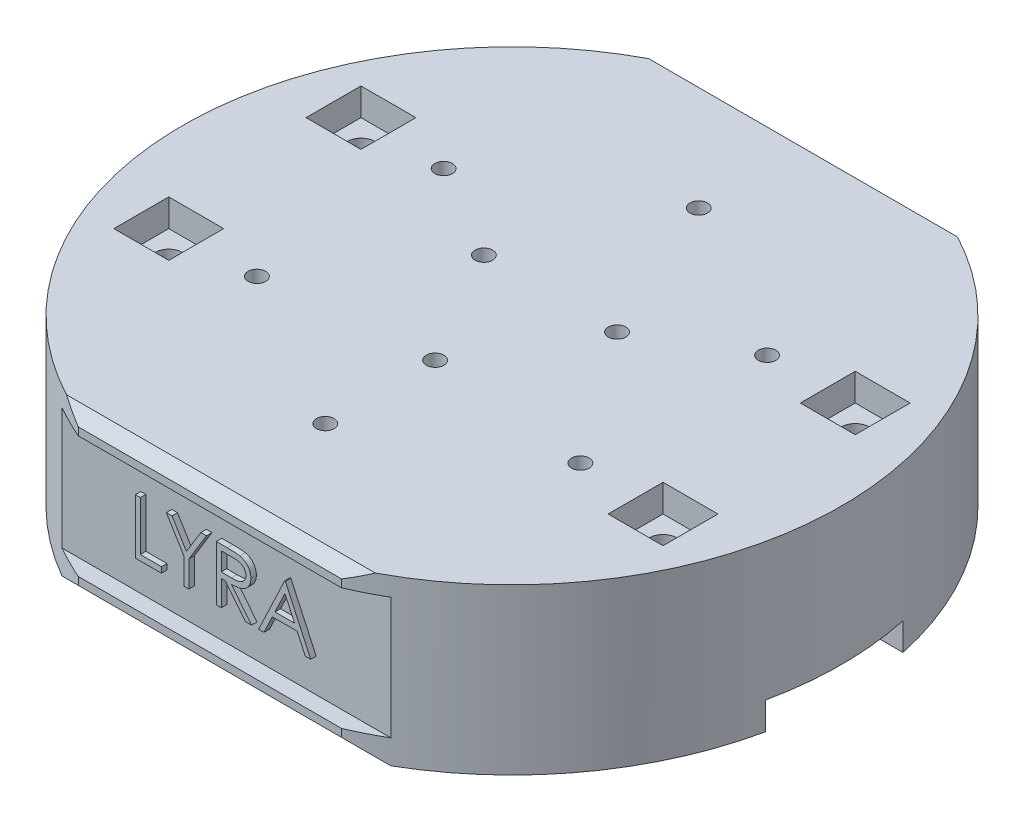
from build123d import *

# Parameters (mm, degrees)
BOSS_EXTRUDE3_DEPTH      = 30
CHAMFER3_SIZE            = 2
CHAMFER4_SIZE            = 3
SKETCH5_R                = 40
CUT_EXTRUDE1_DEPTH       = 10
CHAMFER5_SIZE            = 1
SKETCH8_W                = 101.820371212
SKETCH8_H                = 22.171572876
CUT_EXTRUDE5_DEPTH       = 3
SKETCH9_W                = 3
SKETCH9_H                = 25
CUT_EXTRUDE7_DEPTH       = 5
SKETCH11_W               = 101.820371212
SKETCH11_H               = 22.171572876
CUT_EXTRUDE9_DEPTH       = 3
SKETCH12_R               = 41
CUT_EXTRUDE13_DEPTH      = 10
CUT_EXTRUDE13_DEPTH_BACK = 10
CHAMFER7_SIZE            = 1
SKETCH13_R               = 1.6
CUT_EXTRUDE14_DEPTH      = 20
SKETCH14_R               = 1.6
CUT_EXTRUDE15_DEPTH      = 20
SKETCH18_OUTSIDE_W       = 178.11
SKETCH18_OUTSIDE_H       = 148.11
SKETCH18_OUTSIDE_R       = 60
CUT_EXTRUDE16_DEPTH      = 60
BOSS_EXTRUDE6_DEPTH      = 1
SKETCH21_W               = 10
SKETCH21_H               = 10
CUT_EXTRUDE20_DEPTH      = 5
SKETCH24_R               = 2.5
CUT_EXTRUDE22_DEPTH      = 12


with BuildPart() as part:
    # Sketch2 → Boss-Extrude3 (new body)
    with BuildSketch(Plane(origin=(0, 0, 0), x_dir=(1, 0, 0), z_dir=(0, 1, 0))):
        Polygon((52.324399168, 55), (70, 40.283576004), (70, -40.283576004), (52.324399168, -55), (-52.324399168, -55), (-70, -40.283576004), (-70, 40.283576004), (-52.324399168, 55), align=None)
    extrude(amount=BOSS_EXTRUDE3_DEPTH)

    # Chamfer3
    chamfer3_edges = [part.edges().sort_by_distance(p)[0] for p in [
        (0, 30, 55),
        (61.162199584, 30, 47.641788002),
        (70, 30, 0),
        (61.162199584, 30, -47.641788002),
        (0, 30, -55),
        (-61.162199584, 30, -47.641788002),
        (-70, 30, 0),
        (-61.162199584, 30, 47.641788002),
    ]]
    chamfer(chamfer3_edges, length=CHAMFER3_SIZE)

    # Chamfer4
    chamfer4_edges = [part.edges().sort_by_distance(p)[0] for p in [
        (61.162199584, 0, 47.641788002),
        (0, 0, 55),
        (-61.162199584, 0, 47.641788002),
        (-70, 0, 0),
        (-61.162199584, 0, -47.641788002),
        (0, 0, -55),
        (61.162199584, 0, -47.641788002),
        (70, 0, 0),
    ]]
    chamfer(chamfer4_edges, length=CHAMFER4_SIZE)

    # Sketch5 → Cut-Extrude1 (cut)
    with BuildSketch(Plane.XZ):
        Circle(SKETCH5_R)
    extrude(amount=-CUT_EXTRUDE1_DEPTH, mode=Mode.SUBTRACT)

    # Chamfer5
    chamfer5_edges = [part.edges().sort_by_distance(p)[0] for p in [
        (-40, 0, 0),
    ]]
    chamfer(chamfer5_edges, length=CHAMFER5_SIZE)

    # Sketch8 → Cut-Extrude5 (cut)
    with BuildSketch(Plane.XY.offset(55)):
        with Locations((0, 15.5)):
            Rectangle(SKETCH8_W, SKETCH8_H)
    extrude(amount=-CUT_EXTRUDE5_DEPTH, mode=Mode.SUBTRACT)

    # Sketch9 → Cut-Extrude7 (cut)
    with BuildSketch(Plane.XZ):
        with BuildLine():
            Line((67, 12.5), (39.048047326, 12.5))
            ThreePointArc((39.048047326, 12.5), (40.50907269, 6.32574342), (41, 0))
            ThreePointArc((41, 0), (40.50907269, -6.32574342), (39.048047326, -12.5))
            Line((39.048047326, -12.5), (67, -12.5))
            Line((67, -12.5), (67, 12.5))
        make_face()
        with Locations((68.5, 0)):
            Rectangle(SKETCH9_W, SKETCH9_H)
        with BuildLine():
            Line((39.048047326, 12.5), (37.996710384, 12.5))
            ThreePointArc((37.996710384, 12.5), (40, 0), (37.996710384, -12.5))
            Line((37.996710384, -12.5), (39.048047326, -12.5))
            ThreePointArc((39.048047326, -12.5), (40.50907269, -6.32574342), (41, 0))
            ThreePointArc((41, 0), (40.50907269, 6.32574342), (39.048047326, 12.5))
        make_face()
        with BuildLine():
            Line((-37.996710384, 12.5), (-70, 12.5))
            Line((-70, 12.5), (-70, -12.5))
            Line((-70, -12.5), (-37.996710384, -12.5))
            ThreePointArc((-37.996710384, -12.5), (-40, 0), (-37.996710384, 12.5))
        make_face()
    extrude(amount=-CUT_EXTRUDE7_DEPTH, mode=Mode.SUBTRACT)

    # Sketch11 → Cut-Extrude9 (cut)
    with BuildSketch(Plane(origin=(0, 0, -55), x_dir=(-1, 0, 0), z_dir=(0, 0, -1))):
        with Locations((0, 15.5)):
            Rectangle(SKETCH11_W, SKETCH11_H)
    extrude(amount=-CUT_EXTRUDE9_DEPTH, mode=Mode.SUBTRACT)

    # Sketch12 → Cut-Extrude13 (cut, two sides)
    with BuildSketch(Plane.XZ.offset(-10)) as cut_extrude13_sk:
        Circle(SKETCH12_R)
    extrude(amount=CUT_EXTRUDE13_DEPTH, mode=Mode.SUBTRACT)
    extrude(cut_extrude13_sk.sketch, amount=-CUT_EXTRUDE13_DEPTH_BACK, mode=Mode.SUBTRACT)

    # Chamfer7
    chamfer7_edges = [part.edges().sort_by_distance(p)[0] for p in [
        (0, 0, -41),
    ]]
    chamfer(chamfer7_edges, length=CHAMFER7_SIZE)

    # Sketch13 → Cut-Extrude14 (cut)
    with BuildSketch(Plane.XZ.offset(-20)):
        with Locations((0, 14)):
            Circle(SKETCH13_R)
        with Locations((12.124355653, -7)):
            Circle(SKETCH13_R)
        with Locations((-12.124355653, -7)):
            Circle(SKETCH13_R)
    extrude(amount=-CUT_EXTRUDE14_DEPTH, mode=Mode.SUBTRACT)

    # Sketch14 → Cut-Extrude15 (cut)
    with BuildSketch(Plane.XZ.offset(-20)):
        with Locations((0, 34)):
            Circle(SKETCH14_R)
        with Locations((29.444863729, 17)):
            Circle(SKETCH14_R)
        with Locations((29.444863729, -17)):
            Circle(SKETCH14_R)
        with Locations((0, -34)):
            Circle(SKETCH14_R)
        with Locations((-29.444863729, -17)):
            Circle(SKETCH14_R)
        with Locations((-29.444863729, 17)):
            Circle(SKETCH14_R)
    extrude(amount=-CUT_EXTRUDE15_DEPTH, mode=Mode.SUBTRACT)

    # Sketch18 outside → Cut-Extrude16 (cut)
    with BuildSketch(Plane(origin=(0, 30, 0), x_dir=(1, 0, 0), z_dir=(0, 1, 0))):
        Rectangle(SKETCH18_OUTSIDE_W, SKETCH18_OUTSIDE_H)
        Circle(SKETCH18_OUTSIDE_R, mode=Mode.SUBTRACT)
    extrude(amount=-CUT_EXTRUDE16_DEPTH, mode=Mode.SUBTRACT)

    # Sketch19 → Boss-Extrude6 (add)
    with BuildSketch(Plane.XY.offset(52)):
        Polygon((-15.576923077, 20.5), (-14.679487179, 20.5), (-14.679487179, 11.525641026), (-10.833333333, 11.525641026), (-10.833333333, 10.5), (-15.576923077, 10.5), align=None)
        Polygon((-9.935897436, 20.5), (-8.908253205, 20.5), (-6.280048077, 16.203125), (-3.655849359, 20.5), (-2.628205128, 20.5), (-5.833333333, 15.253605769), (-5.833333333, 10.5), (-6.730769231, 10.5), (-6.730769231, 15.253605769), align=None)
        with BuildLine():
            Line((-0.833333333, 20.5), (1.16786859, 20.5))
            add(Edge.make_bspline(
                [(1.16786859, 20.5), (1.301414671, 20.499555469), (1.557837941, 20.498701919), (1.925190142, 20.493942596), (2.258981848, 20.48030158), (2.559038531, 20.46856277), (2.825354689, 20.447157224), (3.058746948, 20.426698232), (3.258140369, 20.399916344), (3.378842802, 20.375043707), (3.43349359, 20.363782051)],
                knots=[0, 0, 0, 0, 0.000400646, 0.000769285, 0.001102034, 0.001402842, 0.00167002, 0.001903434, 0.002105708, 0.002273069, 0.002273069, 0.002273069, 0.002273069], degree=3))
            add(Edge.make_bspline(
                [(3.43349359, 20.363782051), (3.506655373, 20.345705579), (3.6514182, 20.309938254), (3.85984696, 20.234339395), (4.058459314, 20.146854753), (4.246430241, 20.044101266), (4.422818216, 19.925316181), (4.589441961, 19.792550117), (4.747057571, 19.646529529), (4.8892908, 19.483572839), (5.023402376, 19.312611383), (5.136512737, 19.127743506), (5.234016965, 18.934424856), (5.311647014, 18.730689377), (5.374155509, 18.518512886), (5.418230479, 18.295973467), (5.444662444, 18.064084967), (5.447353459, 17.905919513), (5.448717949, 17.825721154)],
                knots=[0, 0, 0, 0, 0.000225945, 0.00044707, 0.000664092, 0.000876564, 0.0010888, 0.001301225, 0.001515231, 0.001732327, 0.001949488, 0.002166288, 0.002381294, 0.002598178, 0.002819412, 0.003044128, 0.003277954, 0.003518473, 0.003518473, 0.003518473, 0.003518473], degree=3))
            add(Edge.make_bspline(
                [(5.448717949, 17.825721154), (5.444520811, 17.692477998), (5.436331109, 17.43248609), (5.35997367, 17.055169286), (5.234897899, 16.703199815), (5.062545645, 16.37702085), (4.843061429, 16.082990434), (4.579276311, 15.824731991), (4.271043136, 15.608617955), (3.984102233, 15.458752798), (3.730633091, 15.362773059), (3.521966483, 15.295240606), (3.294346547, 15.243063562), (3.049954163, 15.196320328), (2.78777229, 15.161029773), (2.50842932, 15.13518236), (2.21172603, 15.119027935), (2.007900117, 15.116622207), (1.903044872, 15.115384615)],
                knots=[0, 0, 0, 0, 0.000399362, 0.000779259, 0.001149283, 0.001516695, 0.00188168, 0.00224574, 0.002619261, 0.003007206, 0.003213302, 0.003431872, 0.003664606, 0.003913302, 0.004178188, 0.004457849, 0.004754756, 0.005069316, 0.005069316, 0.005069316, 0.005069316], degree=3))
            Line((1.903044872, 15.115384615), (5.576923077, 10.5))
            Line((5.576923077, 10.5), (4.467147436, 10.5))
            Line((4.467147436, 10.5), (0.793269231, 15.115384615))
            Line((0.793269231, 15.115384615), (0.064102564, 15.115384615))
            Line((0.064102564, 15.115384615), (0.064102564, 10.5))
            Line((0.064102564, 10.5), (-0.833333333, 10.5))
            Line((-0.833333333, 10.5), (-0.833333333, 20.5))
        make_face()
        with BuildLine():
            Line((0.064102564, 19.474358974), (0.064102564, 16.141025641))
            Line((0.064102564, 16.141025641), (1.895032051, 16.127003205))
            add(Edge.make_bspline(
                [(1.895032051, 16.127003205), (1.980517877, 16.126965386), (2.146213754, 16.126892082), (2.385929939, 16.138302871), (2.609130259, 16.151283781), (2.814960979, 16.171139054), (3.003514051, 16.19672783), (3.174695232, 16.228736356), (3.328783952, 16.266027964), (3.508494061, 16.323746895), (3.709169865, 16.415192661), (3.927259751, 16.548236943), (4.112980716, 16.715577284), (4.269888894, 16.906930015), (4.395972984, 17.117319298), (4.484864567, 17.34422321), (4.541271545, 17.58191349), (4.547924532, 17.745279512), (4.551282051, 17.827724359)],
                knots=[0, 0, 0, 0, 0.000256418, 0.000497011, 0.000719809, 0.000927109, 0.001117203, 0.001290465, 0.001449339, 0.001592508, 0.00185611, 0.002109007, 0.002355881, 0.002602112, 0.002849125, 0.003088313, 0.0033308, 0.003577853, 0.003577853, 0.003577853, 0.003577853], degree=3))
            add(Edge.make_bspline(
                [(4.551282051, 17.827724359), (4.54784742, 17.908143141), (4.541041233, 18.067503823), (4.485473323, 18.300806424), (4.391503662, 18.52099771), (4.264868696, 18.727181953), (4.110585396, 18.914341198), (3.92967736, 19.074475921), (3.727091088, 19.206617249), (3.537744807, 19.291058336), (3.3685042, 19.342829345), (3.221562314, 19.379261242), (3.055529521, 19.408531153), (2.869599639, 19.431982755), (2.664566408, 19.452139739), (2.439393119, 19.46571625), (2.195573747, 19.473755861), (2.026582515, 19.474153258), (1.939102564, 19.474358974)],
                knots=[0, 0, 0, 0, 0.00024106, 0.000477692, 0.000714689, 0.000956555, 0.001201242, 0.001439631, 0.001678551, 0.001924252, 0.002058571, 0.002209185, 0.002378145, 0.002564001, 0.002771301, 0.002996098, 0.00324062, 0.003503048, 0.003503048, 0.003503048, 0.003503048], degree=3))
            Line((1.939102564, 19.474358974), (0.064102564, 19.474358974))
        make_face(mode=Mode.SUBTRACT)
        Polygon((11.730769231, 20.5), (16.346153846, 10.5), (15.370592949, 10.5), (13.892227564, 13.705128205), (9.358974359, 13.705128205), (7.838541667, 10.5), (6.858974359, 10.5), (11.602564103, 20.5), align=None)
        Polygon((11.656650641, 18.55088141), (9.845753205, 14.730769231), (13.419471154, 14.730769231), align=None, mode=Mode.SUBTRACT)
    extrude(amount=BOSS_EXTRUDE6_DEPTH)

    # Sketch21 → Cut-Extrude20 (cut)
    with BuildSketch(Plane(origin=(0, 30, 0), x_dir=(1, 0, 0), z_dir=(0, 1, 0))):
        with Locations((45, 17.5)):
            Rectangle(SKETCH21_W, SKETCH21_H)
        with Locations((-45, -17.5)):
            Rectangle(SKETCH21_W, SKETCH21_H)
        with Locations((-45, 17.5)):
            Rectangle(SKETCH21_W, SKETCH21_H)
        with Locations((45, -17.5)):
            Rectangle(SKETCH21_W, SKETCH21_H)
    extrude(amount=-CUT_EXTRUDE20_DEPTH, mode=Mode.SUBTRACT)

    # Sketch24 → Cut-Extrude22 (cut)
    with BuildSketch(Plane(origin=(0, 30, 0), x_dir=(1, 0, 0), z_dir=(0, 1, 0))):
        with Locations((-45, 17.5)):
            Circle(SKETCH24_R)
        with Locations((45, 17.5)):
            Circle(SKETCH24_R)
        with Locations((45, -17.5)):
            Circle(SKETCH24_R)
        with Locations((-45, -17.5)):
            Circle(SKETCH24_R)
    extrude(amount=-CUT_EXTRUDE22_DEPTH, mode=Mode.SUBTRACT)


solid = part.part
